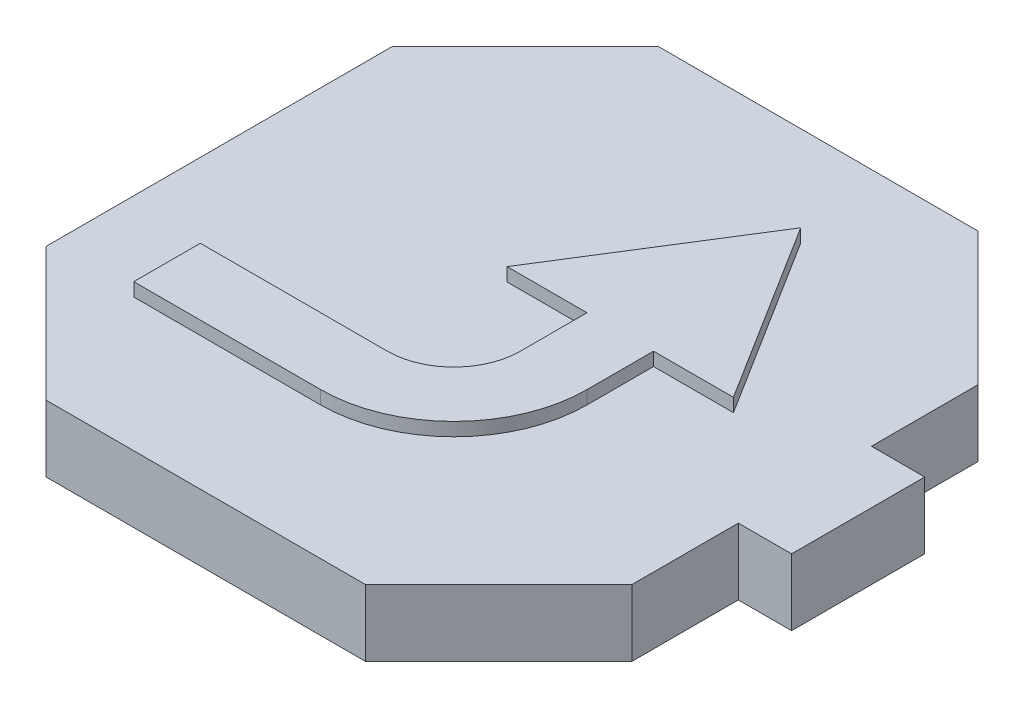
from build123d import *

# Parameters (mm, degrees)
BOSS_EXTRU_1_DEPTH      = 5
BOSS_EXTRU_2_DEPTH      = 1
ESQUISSE3_W             = 5.2
ESQUISSE3_H             = 5.2
ESQUISSE3_W_2           = 5
ESQUISSE3_H_2           = 5
ENL_V_MAT_EXTRU_1_DEPTH = 4.8
CONG_1_R                = 10
CONG_2_R                = 5


with BuildPart() as part:
    # Esquisse1 → Boss.-Extru.1 (new body)
    with BuildSketch(Plane(origin=(0, 0, 0), x_dir=(1, 0, 0), z_dir=(0, 1, 0))):
        Polygon((22, 13), (12.003020456, 23), (-12.003020456, 23), (-22, 13), (-22, -13), (-12.003020456, -23), (12.003020456, -23), (22, -13), (22, -5), (26, -5), (26, 5), (22, 5), align=None)
    extrude(amount=BOSS_EXTRU_1_DEPTH)

    # Esquisse2 → Boss.-Extru.2 (add)
    with BuildSketch(Plane(origin=(0, 5, 0), x_dir=(1, 0, 0), z_dir=(0, 1, 0))):
        Polygon((-15.409608561, -8), (3.631850655, -8), (3.631850655, 2), (-2.368149345, 2), (6.131850655, 15.555441712), (14.631850655, 2), (8.631850655, 2), (8.631850655, -13), (-15.409608561, -13), align=None)
    extrude(amount=BOSS_EXTRU_2_DEPTH)

    # Esquisse3 → Enlèv. mat.-Extru.1 (cut)
    with BuildSketch(Plane.XZ):
        with Locations((-13.4, 14.4)):
            Rectangle(ESQUISSE3_W, ESQUISSE3_H)
        with Locations((-13.4, -14.4)):
            Rectangle(ESQUISSE3_W, ESQUISSE3_H)
        with Locations((14.4, -14.4)):
            Rectangle(ESQUISSE3_W, ESQUISSE3_H)
        with Locations((13.4, 14.4)):
            Rectangle(ESQUISSE3_W, ESQUISSE3_H)
        Rectangle(ESQUISSE3_W_2, ESQUISSE3_H_2)
    extrude(amount=-ENL_V_MAT_EXTRU_1_DEPTH, mode=Mode.SUBTRACT)

    # Congé1
    cong_1_edges = [part.edges().sort_by_distance(p)[0] for p in [
        (8.631850655, 5.5, 13),
    ]]
    fillet(cong_1_edges, radius=CONG_1_R)

    # Congé2
    cong_2_edges = [part.edges().sort_by_distance(p)[0] for p in [
        (3.631850655, 5.5, 8),
    ]]
    fillet(cong_2_edges, radius=CONG_2_R)


solid = part.part
